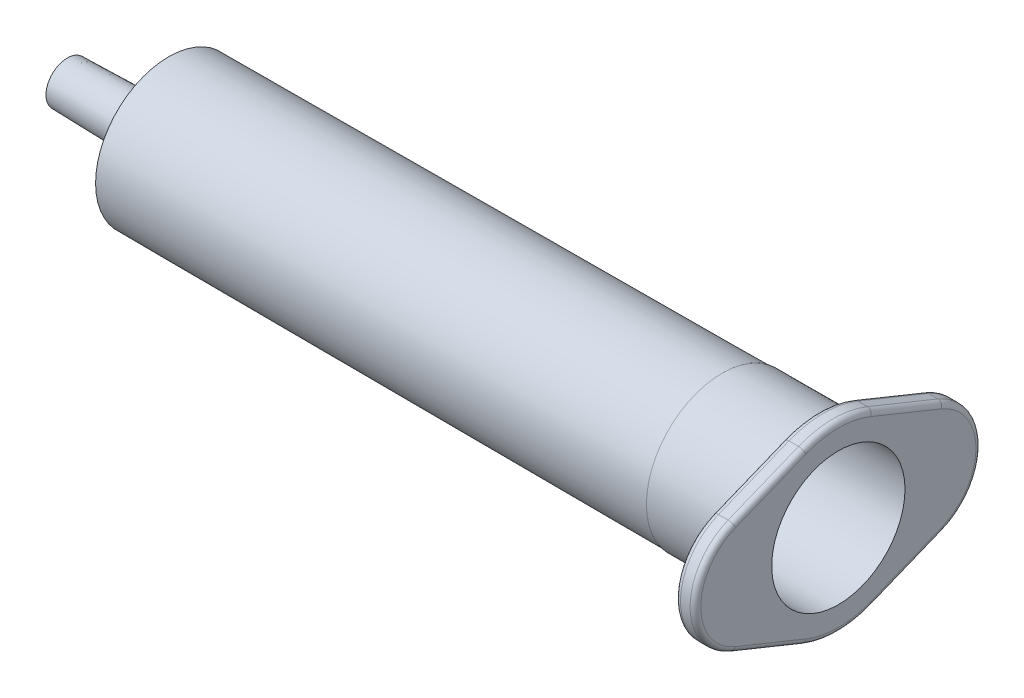
from build123d import *

# Parameters (mm, degrees)
BOSS_EXTRUDE3_DEPTH = 1.9
FILLET4_R           = 8.6
FILLET5_R           = 0.25
FILLET6_R           = 0.5
FILLET7_R           = 1


with BuildPart() as part:
    # Sketch6 → Boss-Extrude3 (new body)
    with BuildSketch(Plane(origin=(72.3, 0, 0), x_dir=(0, 0, -1), z_dir=(1, 0, 0))):
        with BuildLine():
            Line((-9.834595004, -5.292759782), (0, -9.279892888))
            Line((0, -9.279892888), (9.834595004, -5.292759782))
            ThreePointArc((9.834595004, -5.292759782), (13.4, 0), (9.834595004, 5.292759782))
            Line((9.834595004, 5.292759782), (0, 9.279892888))
            Line((0, 9.279892888), (-9.834595004, 5.292759782))
            ThreePointArc((-9.834595004, 5.292759782), (-13.4, 0), (-9.834595004, -5.292759782))
        make_face()
    extrude(amount=-BOSS_EXTRUDE3_DEPTH)

    # Sketch11 → Revolve1 (revolve)
    with BuildSketch(Plane(origin=(0, 0, 0), x_dir=(-1, 0, 0), z_dir=(0, 0, -1))):
        Polygon((-70.4, 7.131416054), (-70.4, 0), (0, 0), (0, 2), (-8.5, 2.2), (-9.5, 6.85), (-61.4, 7.031165912), (-61.4, 7.1), align=None)
    revolve(axis=Axis((70.4, 0, 0), (-1, 0, 0)))

    # Sketch12 → Hole1 (revolve, cut)
    with BuildSketch(Plane(origin=(72.3, 0, 0), x_dir=(0, 0, -1), z_dir=(0, 1, 0))):
        Polygon((0, 0), (0, 72.3), (1, 72.3), (1, 63.239774349), (6.25, 62.110742091), (6.25, 0), align=None)
    revolve(axis=Axis((78.430023899, 0, 0), (-1, 0, 0)), mode=Mode.SUBTRACT)

    # Fillet4
    fillet4_edges = [part.edges().sort_by_distance(p)[0] for p in [
        (71.35, 9.279892888, 0),
        (71.35, -9.279892888, 0),
    ]]
    fillet(fillet4_edges, radius=FILLET4_R)

    # Fillet5
    fillet5_edges = [part.edges().sort_by_distance(p)[0] for p in [
        (9.060225651, 0, 1),
    ]]
    fillet(fillet5_edges, radius=FILLET5_R)

    # Fillet6
    fillet6_edges = [part.edges().sort_by_distance(p)[0] for p in [
        (70.4, 0, -13.4),
        (70.4, 6.631339679, -6.532876496),
        (70.4, -7.131416054, 0),
        (72.3, -6.631339679, -6.532876496),
        (72.3, 6.631339679, 6.532876496),
        (72.3, 8.6, 0),
        (72.3, -8.6, 0),
        (70.4, -6.631339679, -6.532876496),
        (70.4, 6.631339679, 6.532876496),
        (70.4, 8.6, 0),
        (70.4, -8.6, 0),
        (70.4, 0, 13.4),
        (72.3, 6.631339679, -6.532876496),
        (72.3, 0, -13.4),
        (70.4, -6.631339679, 6.532876496),
        (72.3, -6.631339679, 6.532876496),
        (72.3, 0, 13.4),
    ]]
    fillet(fillet6_edges, radius=FILLET6_R)

    # Fillet7
    fillet7_edges = [part.edges().sort_by_distance(p)[0] for p in [
        (8.5, -2.2, 0),
    ]]
    fillet(fillet7_edges, radius=FILLET7_R)


solid = part.part
